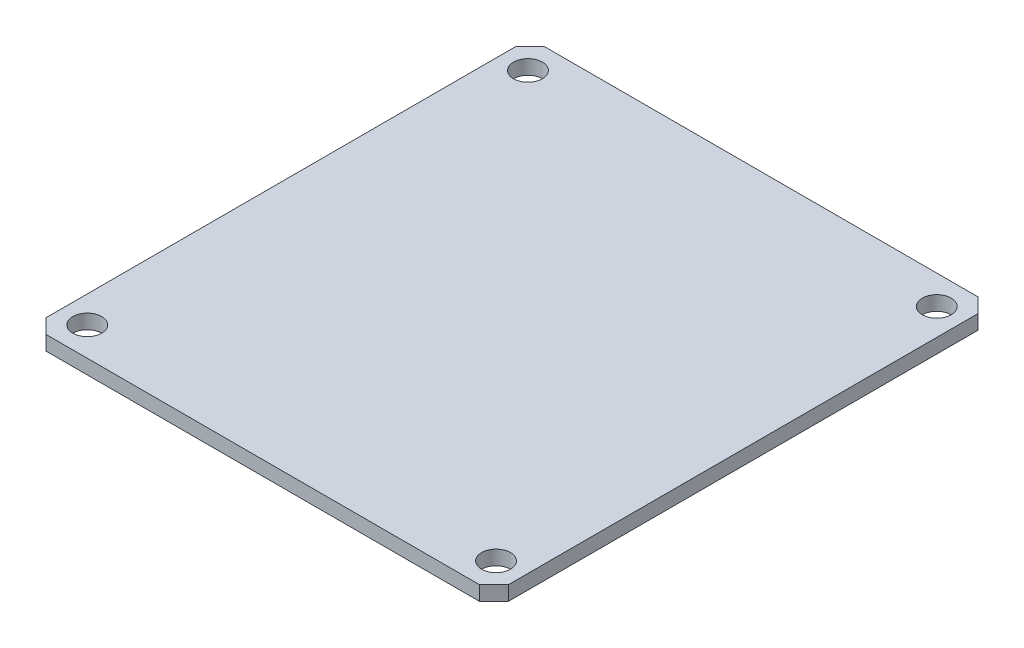
from build123d import *

# Parameters (mm, degrees)
SKETCH1_R           = 2
BOSS_EXTRUDE1_DEPTH = 2


with BuildPart() as part:
    # Sketch1 → Boss-Extrude1 (new body)
    with BuildSketch(Plane(origin=(0, 0, 0), x_dir=(1, 0, 0), z_dir=(0, 1, 0))):
        Polygon((-32, 32.500302023), (-30.000302023, 34.5), (30, 34.5), (32, 32.5), (32, -32.5), (30, -34.5), (-30, -34.5), (-32, -32.5), align=None)
        with Locations((-28.289855072, 30.5)):
            Circle(SKETCH1_R, mode=Mode.SUBTRACT)
        with Locations((28.289570558, 30.500123828)):
            Circle(SKETCH1_R, mode=Mode.SUBTRACT)
        with Locations((-28.289999005, -30.499715485)):
            Circle(SKETCH1_R, mode=Mode.SUBTRACT)
        with Locations((28.289426625, -30.500106318)):
            Circle(SKETCH1_R, mode=Mode.SUBTRACT)
    extrude(amount=BOSS_EXTRUDE1_DEPTH)


solid = part.part
